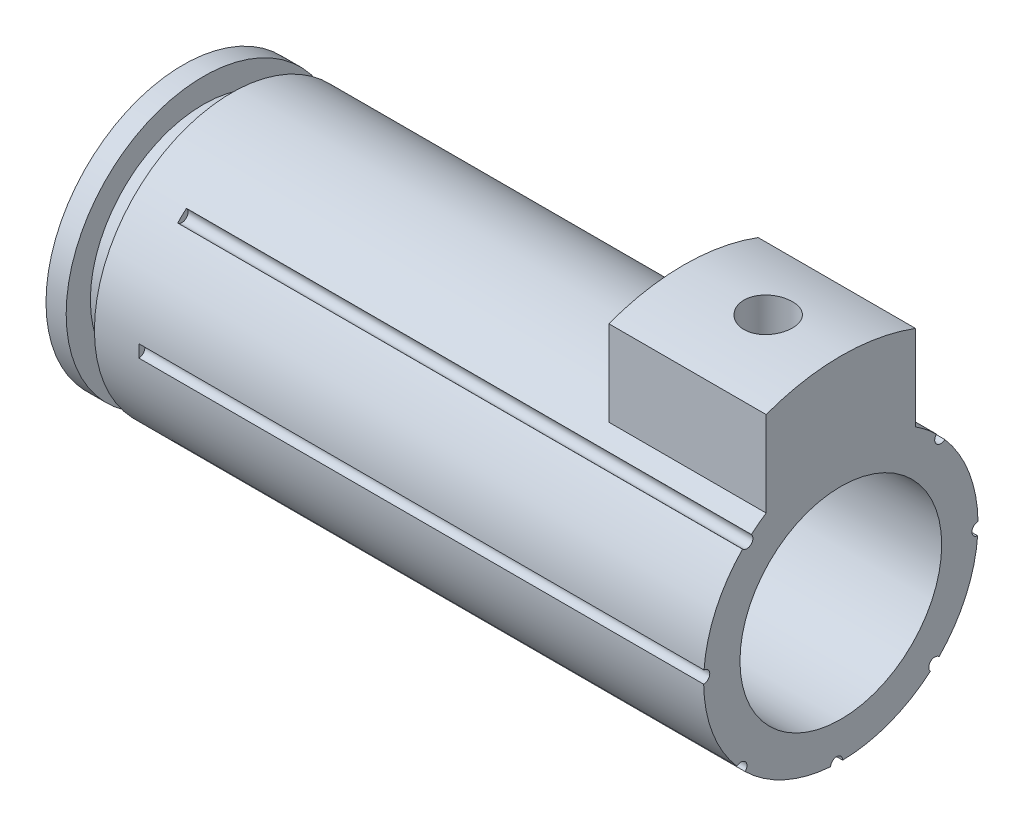
from build123d import *

# Parameters (mm, degrees)
BOSS_EXTRUDE1_DEPTH = 13.462
SKETCH7_OUTSIDE_W   = 29.274
SKETCH7_OUTSIDE_H   = 34.1
SKETCH7_OUTSIDE_R   = 13.462
CUT_EXTRUDE1_DEPTH  = 13.462
SKETCH8_R           = 1.524
CUT_EXTRUDE2_DEPTH  = 6.35
SKETCH9_R           = 6.35
CUT_EXTRUDE3_DEPTH  = 42.402
SKETCH10_R          = 0.381
CUT_EXTRUDE4_DEPTH  = 35.56
CIRPATTERN1_COUNT   = 8


with BuildPart() as part:
    # Sketch1 → Revolve1 (revolve)
    with BuildSketch(Plane.XY):
        Polygon((20.701, 0), (20.701, 8.636), (-17.653, 8.636), (-17.653, 7.112), (-19.431, 7.112), (-19.431, 8.636), (-20.701, 8.636), (-20.701, 0), align=None)
    revolve(axis=Axis((-78.241804248, 0, 0), (1, 0, 0)))

    # Sketch6 → Boss-Extrude1 (add)
    with BuildSketch(Plane(origin=(0, 0, 0), x_dir=(1, 0, 0), z_dir=(0, 1, 0))):
        Polygon((20.701, 0), (20.701, 4.699), (10.795, 4.699), (10.795, -4.699), (20.701, -4.699), align=None)
    extrude(amount=BOSS_EXTRUDE1_DEPTH)

    # Sketch7 outside → Cut-Extrude1 (cut)
    with BuildSketch(Plane(origin=(20.701, 0, 0), x_dir=(0, 0, -1), z_dir=(1, 0, 0))):
        with Locations((0, 2.413)):
            Rectangle(SKETCH7_OUTSIDE_W, SKETCH7_OUTSIDE_H)
        Circle(SKETCH7_OUTSIDE_R, mode=Mode.SUBTRACT)
    extrude(amount=-CUT_EXTRUDE1_DEPTH, mode=Mode.SUBTRACT)

    # Sketch8 → Cut-Extrude2 (cut)
    with BuildSketch(Plane(origin=(0, 13.462, 0), x_dir=(-1, 0, 0), z_dir=(0, 1, 0))):
        with Locations((-16.129, 0)):
            Circle(SKETCH8_R)
    extrude(amount=-CUT_EXTRUDE2_DEPTH, mode=Mode.SUBTRACT)

    # Sketch9 → Cut-Extrude3 (cut, through all)
    with BuildSketch(Plane(origin=(20.701, 0, 0), x_dir=(0, 0, -1), z_dir=(1, 0, 0))):
        Circle(SKETCH9_R)
    extrude(amount=-CUT_EXTRUDE3_DEPTH, mode=Mode.SUBTRACT)

    # Sketch10 → Cut-Extrude4 (cut)
    with BuildSketch(Plane(origin=(20.701, 0, 0), x_dir=(0, 0, -1), z_dir=(1, 0, 0))):
        with Locations((-5.916324211, 6.291073345)):
            Circle(SKETCH10_R)
    cut_extrude4 = extrude(amount=-CUT_EXTRUDE4_DEPTH, mode=Mode.SUBTRACT)

    # CirPattern1: Cut-Extrude4 ×8 about axis, 1 skipped
    cirpattern1_axis = Axis((20.701, 0, 0), (-1, 0, 0))
    add([cut_extrude4.rotate(cirpattern1_axis, i * 360 / CIRPATTERN1_COUNT) for i in range(1, CIRPATTERN1_COUNT) if i not in (1,)], mode=Mode.SUBTRACT)


solid = part.part
